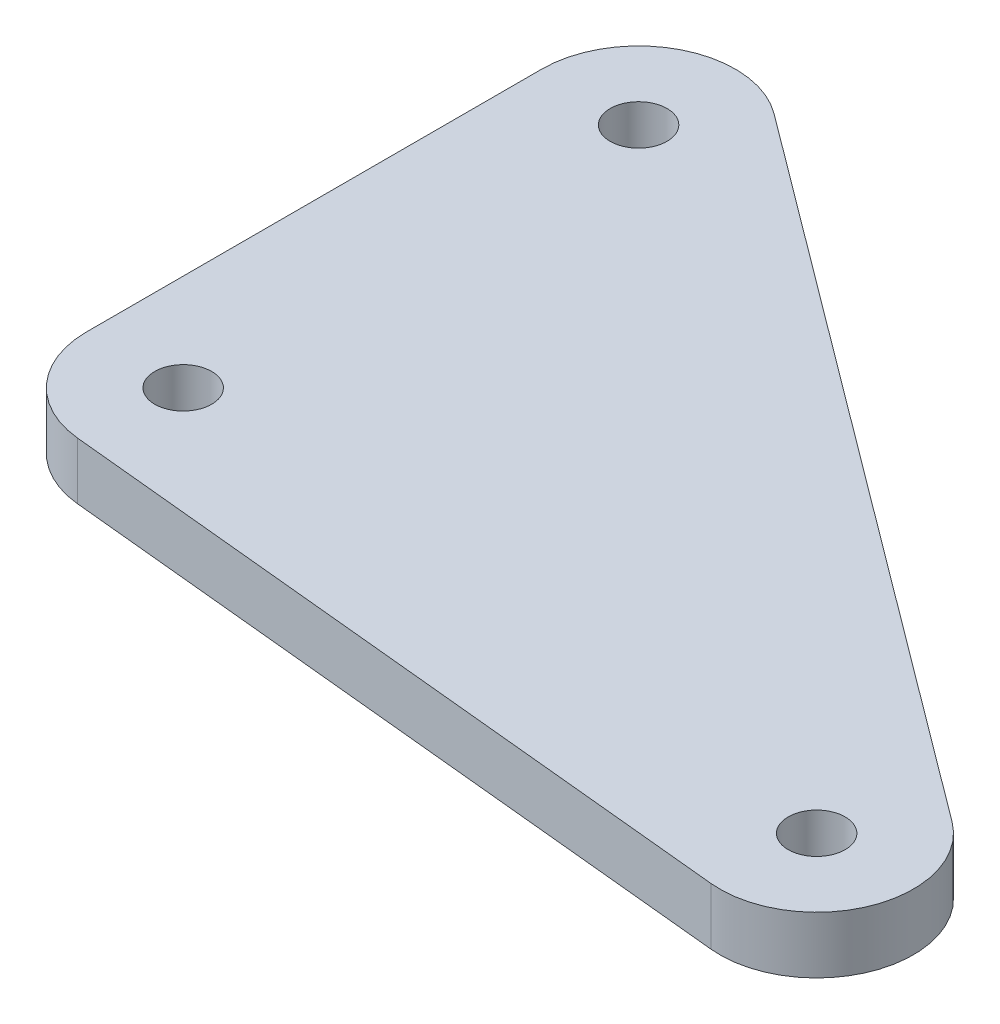
from build123d import *

# Parameters (mm, degrees)
SKETCH1_R           = 1.25
BOSS_EXTRUDE1_DEPTH = 2.5


with BuildPart() as part:
    # Sketch1 → Boss-Extrude1 (new body)
    with BuildSketch(Plane(origin=(0, 0, 0), x_dir=(1, 0, 0), z_dir=(0, 1, 0))):
        with BuildLine():
            Line((2.542410714, 3.405678752), (33.393853524, -19.625571248))
            ThreePointArc((33.393853524, -19.625571248), (34.814441101, -24.566549497), (30.435868213, -27.260883288))
            Line((30.435868213, -27.260883288), (-0.415574597, -24.229633288))
            ThreePointArc((-0.415574597, -24.229633288), (-3.148705451, -22.85449715), (-4.25, -20))
            Line((-4.25, -20), (-4.25, 0))
            ThreePointArc((-4.25, 0), (-1.904895596, 3.7991937), (2.542410714, 3.405678752))
        make_face()
        Circle(SKETCH1_R, mode=Mode.SUBTRACT)
        with Locations((0, -20)):
            Circle(SKETCH1_R, mode=Mode.SUBTRACT)
        with Locations((30.85144281, -23.03125)):
            Circle(SKETCH1_R, mode=Mode.SUBTRACT)
    extrude(amount=BOSS_EXTRUDE1_DEPTH)


solid = part.part
